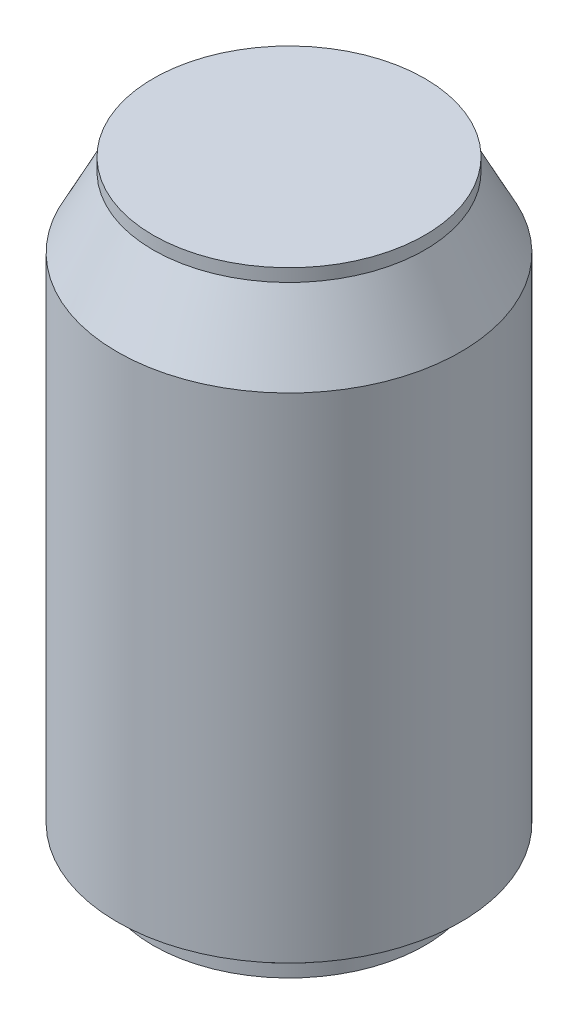
from build123d import *

# Parameters (mm, degrees)
SKETCH2_W           = 19.05
SKETCH2_H           = 19.05
BOSS_EXTRUDE1_DEPTH = 7.62
SKETCH3_W           = 12.7
SKETCH3_H           = 12.7
CUT_EXTRUDE1_DEPTH  = 25.4


with BuildPart() as part:
    # Sketch1 → Revolve1 (revolve)
    with BuildSketch(Plane.XY):
        Polygon((0, 0), (0, 122.2375), (26.9875, 122.2375), (26.9875, 119.6975), (34.13125, 105.7275), (34.13125, 7.62), (26.9875, 2.54), (26.9875, 0), align=None)
    revolve(axis=Axis((0, 0, 0), (0, 1, 0)))

    # Sketch2 → Boss-Extrude1 (add)
    with BuildSketch(Plane.ZY.offset(34.13125)):
        with Locations((0, 17.145)):
            Rectangle(SKETCH2_W, SKETCH2_H)
    extrude(amount=-BOSS_EXTRUDE1_DEPTH)

    # Sketch3 → Cut-Extrude1 (cut)
    with BuildSketch(Plane.XZ):
        with Locations((6.35, 6.35)):
            Rectangle(SKETCH3_W, SKETCH3_H)
    extrude(amount=-CUT_EXTRUDE1_DEPTH, mode=Mode.SUBTRACT)


solid = part.part
